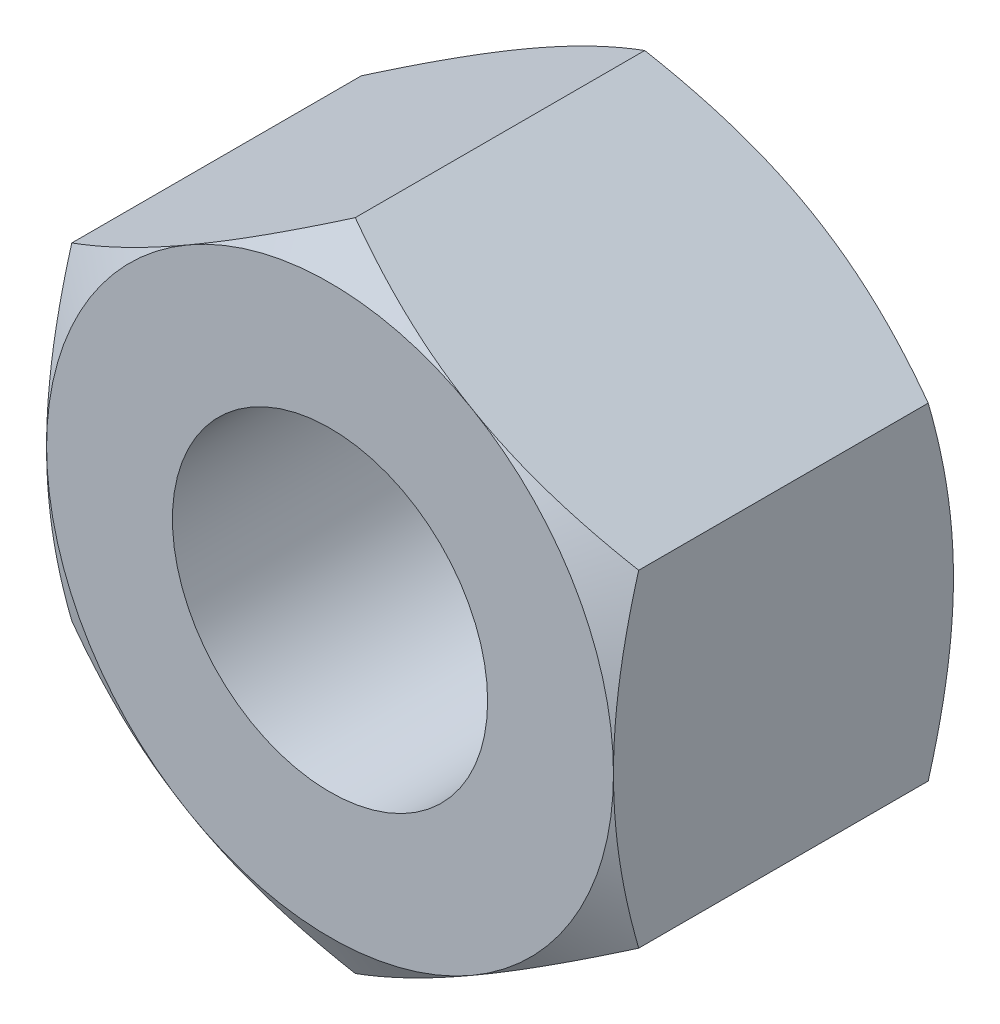
from build123d import *

# Parameters (mm, degrees)
BASENUTSKE_R  = 3.96875
BASENUT_DEPTH = 8.5598


with BuildPart() as part:
    # BaseNutSke → BaseNut (new body)
    with BuildSketch(Plane.XY):
        Polygon((7.1374, 4.120779811), (7.1374, -4.120779811), (0, -8.241559623), (-7.1374, -4.120779811), (-7.1374, 4.120779811), (0, 8.241559623), align=None)
        Circle(BASENUTSKE_R, mode=Mode.SUBTRACT)
    extrude(amount=-BASENUT_DEPTH)

    # Sketch3 → Double-Chamfer (revolve, cut)
    with BuildSketch(Plane(origin=(0, 0, 0), x_dir=(0, 0, -1), z_dir=(1, 0, 0))):
        Polygon((8.5598, 7.1374), (7.9248, 8.241559623), (7.9248, 20.941559623), (21.2598, 20.941559623), (21.2598, 7.1374), align=None)
        Polygon((0.635, 20.941559623), (-12.7, 20.941559623), (-12.7, 7.1374), (0, 7.1374), (0.635, 8.241559623), align=None)
    revolve(axis=Axis((0, 0, 0), (0, 0, -1)), mode=Mode.SUBTRACT)

    # Sketch5 → EndChamfer (revolve, cut)
    with BuildSketch(Plane(origin=(0, 0, 0), x_dir=(0, 0, -1), z_dir=(1, 0, 0))):
        Polygon((8.5344, 3.175), (8.055086934, 2.49047), (8.5852, 2.49047), (8.5852, 3.175), align=None)
        Polygon((-0.0508, 3.175), (0, 3.175), (0.479313066, 2.49047), (-0.0508, 2.49047), align=None)
    revolve(axis=Axis((0, 0, -25.037505729), (0, 0, -1)), mode=Mode.SUBTRACT)


solid = part.part
